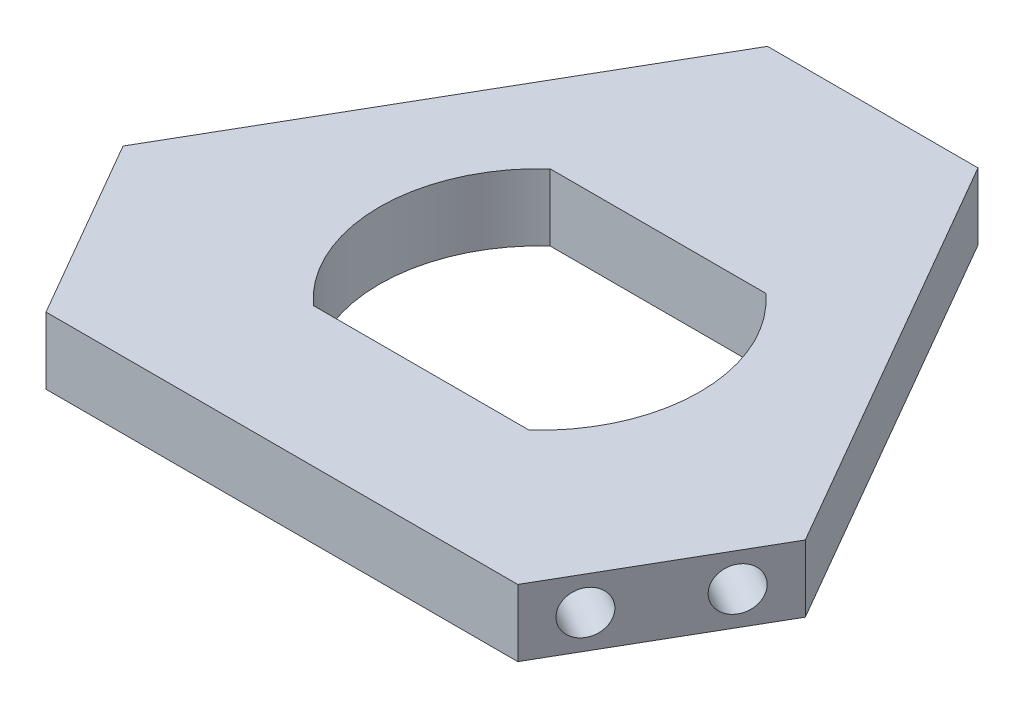
from build123d import *

# Parameters (mm, degrees)
CROQUIS1_W              = 57.5
CROQUIS1_H              = 42.5
SALIENTE_EXTRUIR1_DEPTH = 12
CROQUIS7_R              = 46.25
CROQUIS7_R_2            = 28.75
SALIENTE_EXTRUIR2_DEPTH = 12
CROQUIS8_R              = 3.875
CORTAR_EXTRUIR1_DEPTH   = 10
MATRIZC1_COUNT          = 3


with BuildPart() as part:
    # Croquis1 → Saliente-Extruir1 (new body)
    with BuildSketch(Plane(origin=(0, 0, 0), x_dir=(1, 0, 0), z_dir=(0, 1, 0))):
        Polygon((-18.886751346, 59.787187079), (-61.220598504, -13.537187079), (-42.333847158, -46.25), (42.333847158, -46.25), (61.220598504, -13.537187079), (18.886751346, 59.787187079), align=None)
        Rectangle(CROQUIS1_W, CROQUIS1_H, mode=Mode.SUBTRACT)
    extrude(amount=SALIENTE_EXTRUIR1_DEPTH)

    # Croquis7 → Saliente-Extruir2 (add)
    with BuildSketch(Plane(origin=(0, 0, 0), x_dir=(1, 0, 0), z_dir=(0, 1, 0))):
        Circle(CROQUIS7_R)
        Circle(CROQUIS7_R_2, mode=Mode.SUBTRACT)
    extrude(amount=SALIENTE_EXTRUIR2_DEPTH)

    # Croquis8 → Cortar-Extruir1 (cut)
    with BuildSketch(Plane(origin=(51.777222831, 0, 29.893593539), x_dir=(0.5, 0, -0.866025404), z_dir=(0.866025404, 0, 0.5))):
        with Locations((-10, 6)):
            Circle(CROQUIS8_R)
        with Locations((10, 6)):
            Circle(CROQUIS8_R)
    cortar_extruir1 = extrude(amount=-CORTAR_EXTRUIR1_DEPTH, mode=Mode.SUBTRACT)

    # MatrizC1: Cortar-Extruir1 ×3 about axis
    matrizc1_axis = Axis((0, 0, 0), (0, 1, 0))
    for i in range(1, MATRIZC1_COUNT):
        add(cortar_extruir1.rotate(matrizc1_axis, i * 360 / MATRIZC1_COUNT), mode=Mode.SUBTRACT)


solid = part.part
